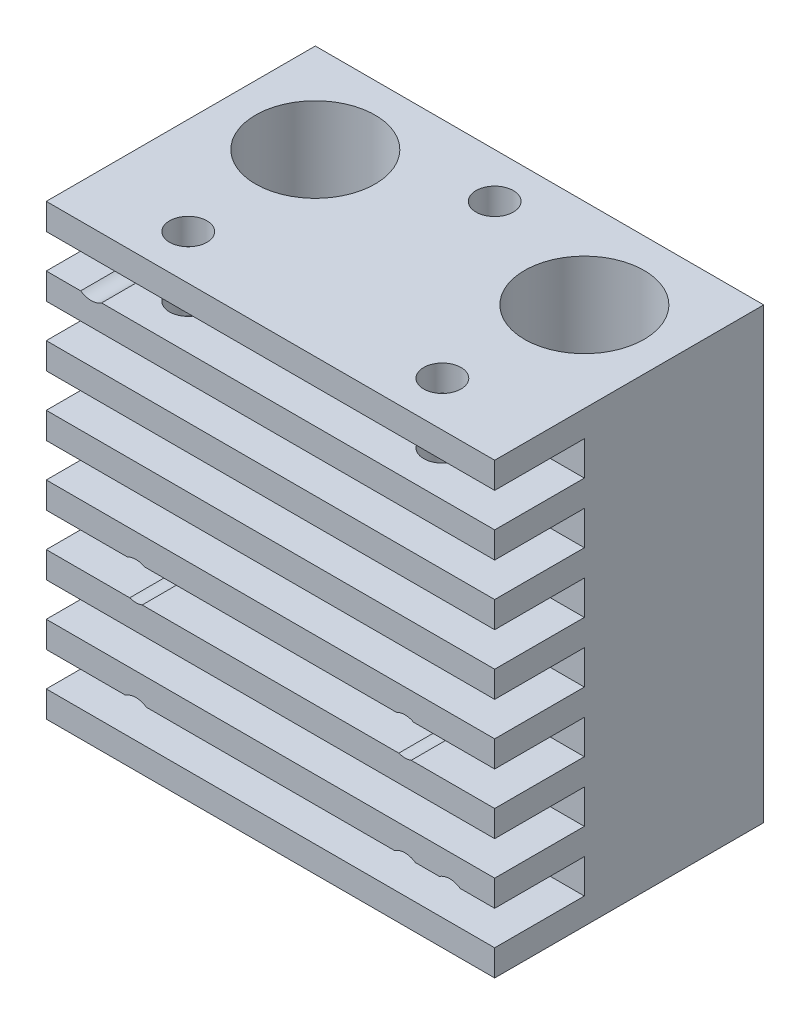
from build123d import *

# Parameters (mm, degrees)
BOSS_EXTRUDE1_DEPTH             = 15
TAP_DRILL_FOR_M3X0_5_TAP2_D     = 2.5
TAP_DRILL_FOR_M3X0_5_TAP2_DEPTH = 5
TAP_DRILL_FOR_M3X0_5_TAP2_TIP   = 0.751075774
F_7_0_7_DIAMETER_HOLE1_D        = 7
F_7_0_7_DIAMETER_HOLE1_DEPTH    = 14
F_7_0_7_DIAMETER_HOLE1_TIP      = 2.103012167
F_8_0_8_DIAMETER_HOLE1_D        = 8
F_8_0_8_DIAMETER_HOLE1_DEPTH    = 6.5
F_8_0_8_DIAMETER_HOLE1_TIP      = 2.403442476
F_4_2_4_2_DIAMETER_HOLE1_D      = 4.2
M3X0_5_TAPPED_HOLE1_D           = 2.5
M3X0_5_TAPPED_HOLE2_D           = 2.5
M3X0_5_TAPPED_HOLE2_DEPTH       = 6
M3X0_5_TAPPED_HOLE2_TIP         = 0.751075774
M3X0_5_TAPPED_HOLE3_D           = 2.5
M3X0_5_TAPPED_HOLE3_DEPTH       = 8
M3X0_5_TAPPED_HOLE3_TIP         = 0.751075774


with BuildPart() as part:
    # Sketch1 → Boss-Extrude1 (new body, symmetric)
    with BuildSketch(Plane(origin=(0, 0, 0), x_dir=(0, 0, -1), z_dir=(1, 0, 0))):
        Polygon((-9, 15), (-9, 13.25), (-3, 13.25), (-3, 10.964285714), (-9, 10.964285714), (-9, 9.214285714), (-3, 9.214285714), (-3, 6.928571429), (-9, 6.928571429), (-9, 5.178571429), (-3, 5.178571429), (-3, 2.892857143), (-9, 2.892857143), (-9, 1.142857143), (-3, 1.142857143), (-3, -1.142857143), (-9, -1.142857143), (-9, -2.892857143), (-3, -2.892857143), (-3, -5.178571429), (-9, -5.178571429), (-9, -6.928571429), (-3, -6.928571429), (-3, -9.214285714), (-9, -9.214285714), (-9, -10.964285714), (-3, -10.964285714), (-3, -13.25), (-9, -13.25), (-9, -15), (9, -15), (9, 15), align=None)
    extrude(amount=BOSS_EXTRUDE1_DEPTH, both=True)

    # Tap Drill for M3x0.5 Tap2
    with Locations(Plane.XY.offset(9)):
        with Locations((-12, 12), (12, -12)):
            Hole(TAP_DRILL_FOR_M3X0_5_TAP2_D / 2, depth=TAP_DRILL_FOR_M3X0_5_TAP2_DEPTH)
            with Locations((0, 0, -(TAP_DRILL_FOR_M3X0_5_TAP2_DEPTH + TAP_DRILL_FOR_M3X0_5_TAP2_TIP / 2))):  # 118° drill point
                Cone(0, TAP_DRILL_FOR_M3X0_5_TAP2_D / 2, TAP_DRILL_FOR_M3X0_5_TAP2_TIP, mode=Mode.SUBTRACT)

    # Ø7.0 (7) Diameter Hole1
    with Locations(Plane(origin=(0, -15, 0), x_dir=(-1, 0, 0), z_dir=(0, -1, 0))):
        with Locations((9, 3), (-9, 3)):
            Hole(F_7_0_7_DIAMETER_HOLE1_D / 2, depth=F_7_0_7_DIAMETER_HOLE1_DEPTH)
            with Locations((0, 0, -(F_7_0_7_DIAMETER_HOLE1_DEPTH + F_7_0_7_DIAMETER_HOLE1_TIP / 2))):  # 118° drill point
                Cone(0, F_7_0_7_DIAMETER_HOLE1_D / 2, F_7_0_7_DIAMETER_HOLE1_TIP, mode=Mode.SUBTRACT)

    # Ø8.0 (8) Diameter Hole1
    with Locations(Plane(origin=(0, 15, 0), x_dir=(1, 0, 0), z_dir=(0, 1, 0))):
        with Locations((-9, 3), (9, 3)):
            Hole(F_8_0_8_DIAMETER_HOLE1_D / 2, depth=F_8_0_8_DIAMETER_HOLE1_DEPTH)
            with Locations((0, 0, -(F_8_0_8_DIAMETER_HOLE1_DEPTH + F_8_0_8_DIAMETER_HOLE1_TIP / 2))):  # 118° drill point
                Cone(0, F_8_0_8_DIAMETER_HOLE1_D / 2, F_8_0_8_DIAMETER_HOLE1_TIP, mode=Mode.SUBTRACT)

    # Ø4.2 (4.2) Diameter Hole1 (through all)
    with Locations(Plane(origin=(0, 15, 0), x_dir=(1, 0, 0), z_dir=(0, 1, 0))):
        with Locations((-9, 3), (9, 3)):
            Hole(F_4_2_4_2_DIAMETER_HOLE1_D / 2)

    # M3x0.5 Tapped Hole1 (through all)
    with Locations(Plane(origin=(0, 0, -9), x_dir=(-1, 0, 0), z_dir=(0, 0, -1))):
        with Locations((-9, -12), (-9, -4), (9, -4), (9, -12)):
            Hole(M3X0_5_TAPPED_HOLE1_D / 2)

    # M3x0.5 Tapped Hole2
    with Locations(Plane(origin=(0, 15, 0), x_dir=(1, 0, 0), z_dir=(0, 1, 0))):
        with Locations((-8.5, -6), (8.5, -6), (0, 6)):
            Hole(M3X0_5_TAPPED_HOLE2_D / 2, depth=M3X0_5_TAPPED_HOLE2_DEPTH)
            with Locations((0, 0, -(M3X0_5_TAPPED_HOLE2_DEPTH + M3X0_5_TAPPED_HOLE2_TIP / 2))):  # 118° drill point
                Cone(0, M3X0_5_TAPPED_HOLE2_D / 2, M3X0_5_TAPPED_HOLE2_TIP, mode=Mode.SUBTRACT)

    # M3x0.5 Tapped Hole3
    with Locations(Plane(origin=(0, 0, -9), x_dir=(-1, 0, 0), z_dir=(0, 0, -1))):
        with Locations((-4.5, 5), (4.5, 5), (0, -5)):
            Hole(M3X0_5_TAPPED_HOLE3_D / 2, depth=M3X0_5_TAPPED_HOLE3_DEPTH)
            with Locations((0, 0, -(M3X0_5_TAPPED_HOLE3_DEPTH + M3X0_5_TAPPED_HOLE3_TIP / 2))):  # 118° drill point
                Cone(0, M3X0_5_TAPPED_HOLE3_D / 2, M3X0_5_TAPPED_HOLE3_TIP, mode=Mode.SUBTRACT)


solid = part.part
